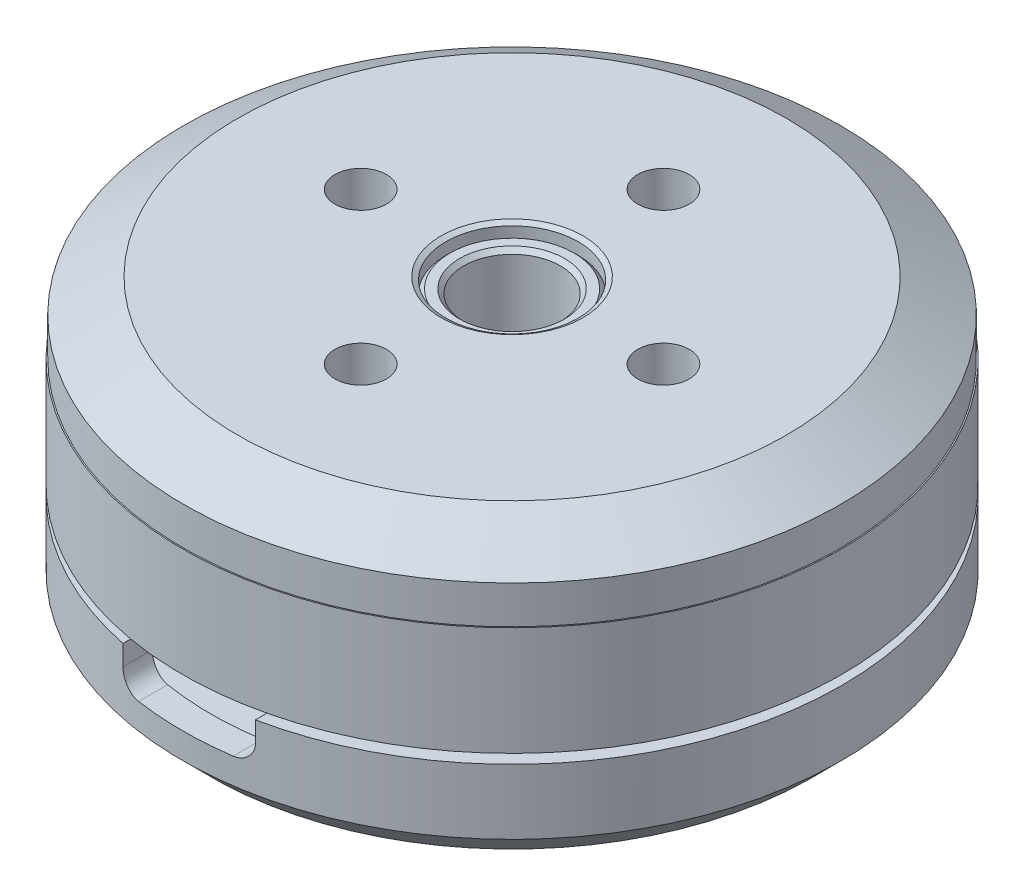
from build123d import *

# Parameters (mm, degrees)
SKETCH4_R          = 1.36
CUT_EXTRUDE1_DEPTH = 4
SKETCH5_R          = 1.36
CUT_EXTRUDE2_DEPTH = 4
SKETCH6_W          = 5.726444475
SKETCH6_H          = 2.29057779
CUT_EXTRUDE3_DEPTH = 3.5
FILLET1_R          = 1


with BuildPart() as part:
    # Sketch1 → Revolve1 (revolve)
    with BuildSketch(Plane(origin=(0, 0, 0), x_dir=(0, 0, -1), z_dir=(1, 0, 0))):
        Polygon((15.9, 0), (3.25, 0), (3.25, -0.75), (3.5, -0.75), (3.5, -1.2), (3.2, -1.5), (2.55, -1.5), (2.55, 14.175), (2.775, 14.4), (3.275, 14.4), (3.5, 14.175), (3.5, 14.805662433), (3.75, 14.95), (14.5, 14.95), (17.35, 13.2), (17.35, 11.2), (17.415, 11.2), (17.415, 5.45), (16.415, 5.45), (16.415, 11.42717663), (12.5, 13.831123999), (12.5, 4.95), (12.5, 2), (15.9, 2), (15.9, 4.95), (17.415, 4.95), (17.415, 1.515), align=None)
    revolve(axis=Axis((0, 0, 0), (0, 1, 0)))

    # Sketch3 → Cut-Revolve1 (revolve, cut)
    with BuildSketch(Plane(origin=(0, 0, 0), x_dir=(0, 0, -1), z_dir=(1, 0, 0))):
        Polygon((5.5, 0), (5.5, -0.625659235), (3.25, -0.071654916), (3.25, 0.040355339), (3.285355339, 0.005), (3.714644661, 0.005), (3.75, 0.040355339), (3.75, 0.065), (5, 0.065), (5, 0.040355339), (5.035355339, 0.005), (5.464644661, 0.005), (5.5, 0.040355339), align=None)
    revolve(axis=Axis((0, 0, 0), (0, 1, 0)), mode=Mode.SUBTRACT)

    # Sketch4 → Cut-Extrude1 (cut)
    with BuildSketch(Plane(origin=(0, 14.95, 0), x_dir=(1, 0, 0), z_dir=(0, 1, 0))):
        with Locations((0, 8)):
            Circle(SKETCH4_R)
        with Locations((8, 0)):
            Circle(SKETCH4_R)
        with Locations((0, -8)):
            Circle(SKETCH4_R)
        with Locations((-8, 0)):
            Circle(SKETCH4_R)
    extrude(amount=-CUT_EXTRUDE1_DEPTH, mode=Mode.SUBTRACT)

    # Sketch5 → Cut-Extrude2 (cut)
    with BuildSketch(Plane.XZ):
        with Locations((-6.717514421, -6.717514421)):
            Circle(SKETCH5_R)
        with Locations((5.656854249, -5.656854249)):
            Circle(SKETCH5_R)
        with Locations((-5.656854249, 5.656854249)):
            Circle(SKETCH5_R)
        with Locations((6.717514421, 6.717514421)):
            Circle(SKETCH5_R)
    extrude(amount=-CUT_EXTRUDE2_DEPTH, mode=Mode.SUBTRACT)

    # Sketch6 → Cut-Extrude3 (cut, symmetric)
    with BuildSketch(Plane(origin=(0, 0, 0), x_dir=(0, 0, -1), z_dir=(1, 0, 0))):
        with Locations((-15.363222238, 4.025390462)):
            Rectangle(SKETCH6_W, SKETCH6_H)
    extrude(amount=CUT_EXTRUDE3_DEPTH, both=True, mode=Mode.SUBTRACT)

    # Fillet1
    fillet1_edges = [part.edges().sort_by_distance(p)[0] for p in [
        (-3.5, 2.880101567, 16.284831695),
        (3.5, 2.880101567, 16.284831695),
    ]]
    fillet(fillet1_edges, radius=FILLET1_R)


solid = part.part
